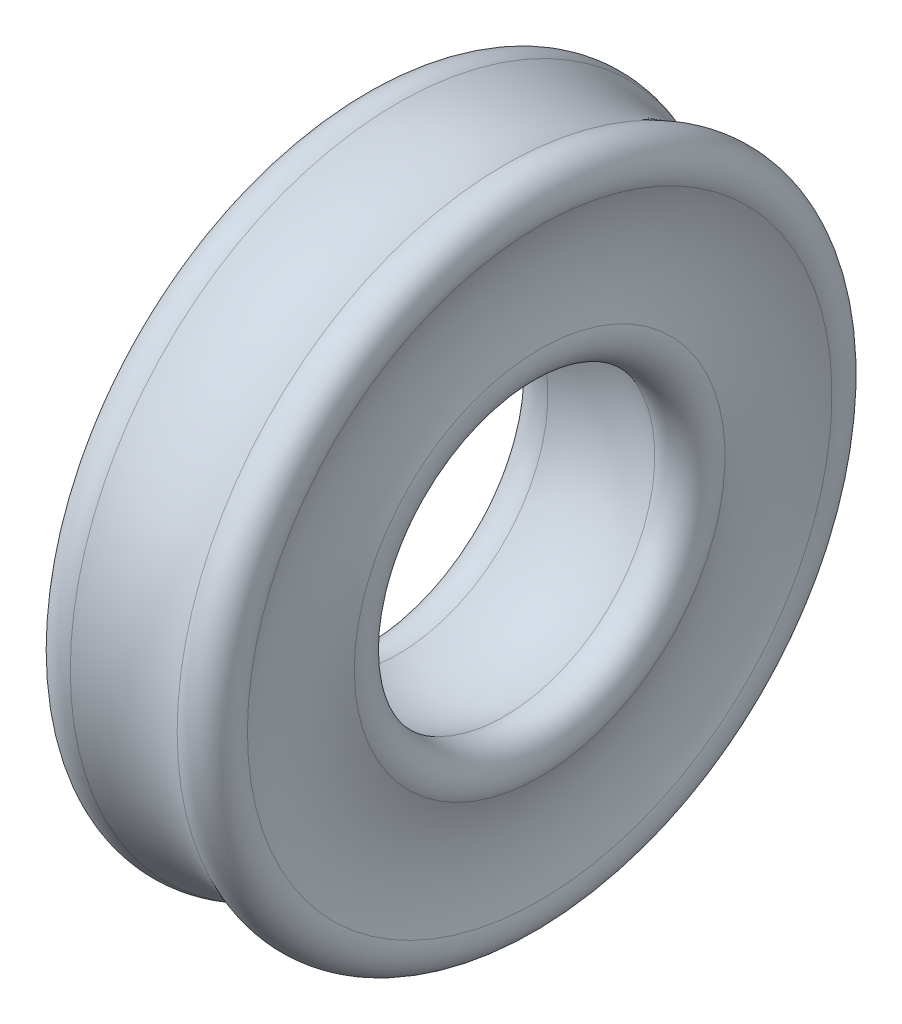
from build123d import *


with BuildPart() as part:
    # Sketch1 → Revolve1 (revolve)
    with BuildSketch(Plane.XY, mode=Mode.PRIVATE) as revolve1_sk:
        with BuildLine():
            ThreePointArc((-0.86657475, 2.859704285), (-0.75565, 2.3368), (-0.86657475, 1.813895715))
            ThreePointArc((-0.86657475, 1.813895715), (-0.812735857, 1.524064143), (-0.522904285, 1.47022525))
            ThreePointArc((-0.522904285, 1.47022525), (0, 1.58115), (0.522904285, 1.47022525))
            ThreePointArc((0.522904285, 1.47022525), (0.812735857, 1.524064143), (0.86657475, 1.813895715))
            ThreePointArc((0.86657475, 1.813895715), (0.75565, 2.3368), (0.86657475, 2.859704285))
            ThreePointArc((0.86657475, 2.859704285), (0.812735857, 3.149535857), (0.522904285, 3.20337475))
            ThreePointArc((0.522904285, 3.20337475), (0, 3.09245), (-0.522904285, 3.20337475))
            ThreePointArc((-0.522904285, 3.20337475), (-0.812735857, 3.149535857), (-0.86657475, 2.859704285))
        make_face()
    revolve(revolve1_sk.sketch.rotate(Axis((-0.889, 0, 0), (1, 0, 0)), 90), axis=Axis((-0.889, 0, 0), (1, 0, 0)))


solid = part.part
